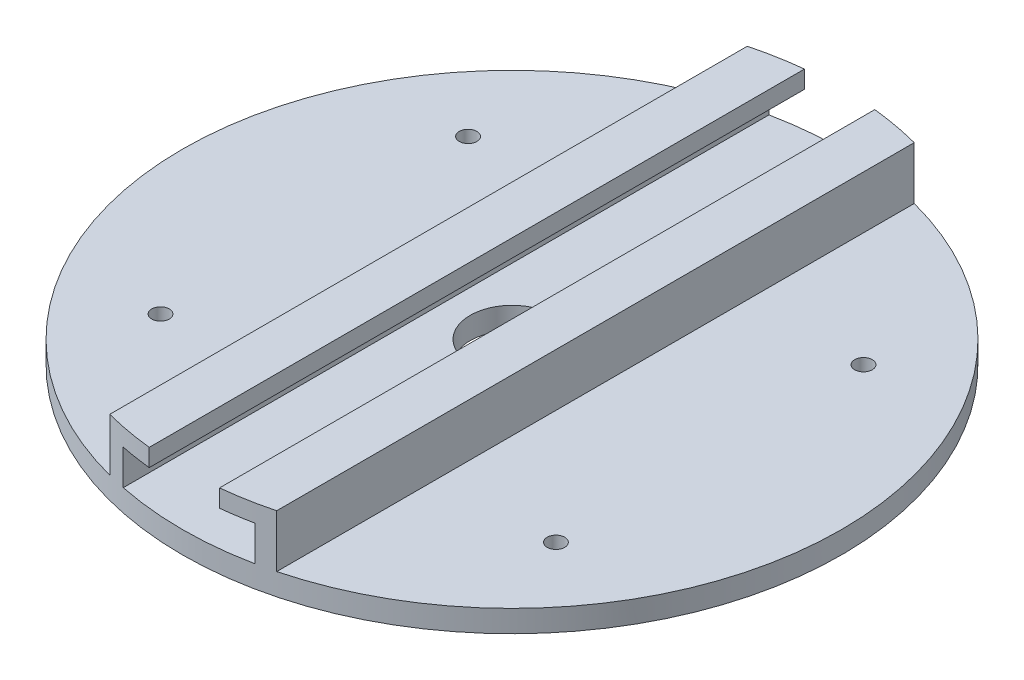
from build123d import *

# Parameters (mm, degrees)
SKETCH1_R                            = 75
BOSS_EXTRUDE1_DEPTH                  = 5
BOSS_EXTRUDE2_REACH                  = 108.184
BOSS_EXTRUDE2_END_RADIUS             = 75
BOSS_EXTRUDE2_DIRECTION_2_REACH      = 108.184
BOSS_EXTRUDE2_DIRECTION_2_END_RADIUS = 75
SKETCH3_R                            = 9.5
CUT_EXTRUDE1_DEPTH                   = 107.742681248
SKETCH4_R                            = 2
CUT_EXTRUDE2_DEPTH                   = 107.742681248


with BuildPart() as part:
    # Sketch1 → Boss-Extrude1 (new body)
    with BuildSketch(Plane(origin=(0, 0, 0), x_dir=(1, 0, 0), z_dir=(0, 1, 0))):
        with Locations(Location((0, 0, 0), (0, 0, 270))):
            Circle(SKETCH1_R)
    extrude(amount=BOSS_EXTRUDE1_DEPTH)

    # Boss-Extrude2: up to this cylinder (the profile starts inside it)
    boss_extrude2_end = Plane(origin=(0, 12, 0), z_dir=(0, -1, 0)) * Cylinder(BOSS_EXTRUDE2_END_RADIUS, 373.368, mode=Mode.PRIVATE)
    # Sketch2 → Boss-Extrude2 (add, up to the surface)
    with BuildSketch(Plane.XY, mode=Mode.PRIVATE) as boss_extrude2_sk1:
        Polygon((-15, 5), (-15, 13), (-8, 13), (-8, 17), (-19, 17), (-19, 5), align=None)
    boss_extrude2_tool1 = extrude(boss_extrude2_sk1.sketch, amount=BOSS_EXTRUDE2_REACH, mode=Mode.PRIVATE) & boss_extrude2_end
    add(boss_extrude2_tool1.solids().sort_by_distance((-15.162788, 9, 0))[0])
    # Sketch2 → Boss-Extrude2 (add, up to the surface)
    with BuildSketch(Plane.XY, mode=Mode.PRIVATE) as boss_extrude2_sk2:
        Polygon((8, 17), (8, 13), (15, 13), (15, 5), (19, 5), (19, 17), align=None)
    boss_extrude2_tool2 = extrude(boss_extrude2_sk2.sketch, amount=BOSS_EXTRUDE2_REACH, mode=Mode.PRIVATE) & boss_extrude2_end
    add(boss_extrude2_tool2.solids().sort_by_distance((8.162788, 15, 0))[0])

    # Boss-Extrude2 direction 2: up to this cylinder (the profile starts inside it)
    boss_extrude2_direction_2_end = Plane(origin=(0, 12, 0), z_dir=(0, -1, 0)) * Cylinder(BOSS_EXTRUDE2_DIRECTION_2_END_RADIUS, 373.368, mode=Mode.PRIVATE)
    # Sketch2 → Boss-Extrude2 direction 2 (add, up to the surface)
    with BuildSketch(Plane.XY, mode=Mode.PRIVATE) as boss_extrude2_direction_2_sk1:
        Polygon((-15, 5), (-15, 13), (-8, 13), (-8, 17), (-19, 17), (-19, 5), align=None)
    boss_extrude2_direction_2_tool1 = extrude(boss_extrude2_direction_2_sk1.sketch, amount=-BOSS_EXTRUDE2_DIRECTION_2_REACH, mode=Mode.PRIVATE) & boss_extrude2_direction_2_end
    add(boss_extrude2_direction_2_tool1.solids().sort_by_distance((-15.162788, 9, 0))[0])
    # Sketch2 → Boss-Extrude2 direction 2 (add, up to the surface)
    with BuildSketch(Plane.XY, mode=Mode.PRIVATE) as boss_extrude2_direction_2_sk2:
        Polygon((8, 17), (8, 13), (15, 13), (15, 5), (19, 5), (19, 17), align=None)
    boss_extrude2_direction_2_tool2 = extrude(boss_extrude2_direction_2_sk2.sketch, amount=-BOSS_EXTRUDE2_DIRECTION_2_REACH, mode=Mode.PRIVATE) & boss_extrude2_direction_2_end
    add(boss_extrude2_direction_2_tool2.solids().sort_by_distance((8.162788, 15, 0))[0])

    # Sketch3 → Cut-Extrude1 (cut, through all)
    with BuildSketch(Plane(origin=(0, 5, 0), x_dir=(1, 0, 0), z_dir=(0, 1, 0))):
        with Locations(Location((0, 0, 0), (0, 0, 270))):
            Circle(SKETCH3_R)
    extrude(amount=-CUT_EXTRUDE1_DEPTH, mode=Mode.SUBTRACT)

    # Sketch4 → Cut-Extrude2 (cut, through all)
    with BuildSketch(Plane(origin=(0, 5, 0), x_dir=(1, 0, 0), z_dir=(0, 1, 0))):
        with Locations(Location((-45, 35, 0), (0, 0, 270))):
            Circle(SKETCH4_R)
        with Locations(Location((45, 35, 0), (0, 0, 270))):
            Circle(SKETCH4_R)
        with Locations(Location((45, -35, 0), (0, 0, 270))):
            Circle(SKETCH4_R)
        with Locations(Location((-45, -35, 0), (0, 0, 270))):
            Circle(SKETCH4_R)
    extrude(amount=-CUT_EXTRUDE2_DEPTH, mode=Mode.SUBTRACT)


solid = part.part
